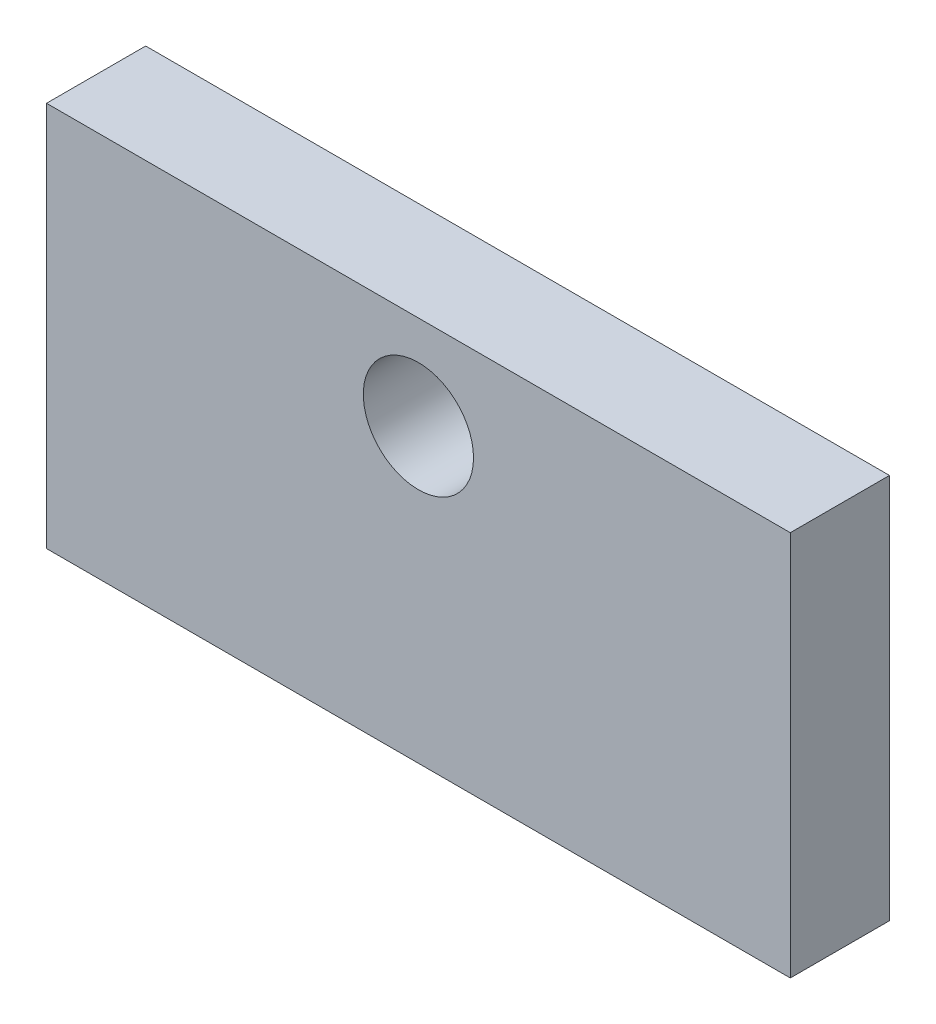
from build123d import *

# Parameters (mm, degrees)
CROQUIS1_W              = 135
CROQUIS1_H              = 70
SALIENTE_EXTRUIR1_DEPTH = 18
CROQUIS3_R              = 10
CORTAR_EXTRUIR1_DEPTH   = 19


with BuildPart() as part:
    # Croquis1 → Saliente-Extruir1 (new body)
    with BuildSketch(Plane.XY):
        with Locations((67.5, 35)):
            Rectangle(CROQUIS1_W, CROQUIS1_H)
    extrude(amount=SALIENTE_EXTRUIR1_DEPTH)

    # Croquis3 → Cortar-Extruir1 (cut, through all)
    with BuildSketch(Plane.XY.offset(18)):
        with Locations((67.5, 53)):
            Circle(CROQUIS3_R)
    extrude(amount=-CORTAR_EXTRUIR1_DEPTH, mode=Mode.SUBTRACT)


solid = part.part
